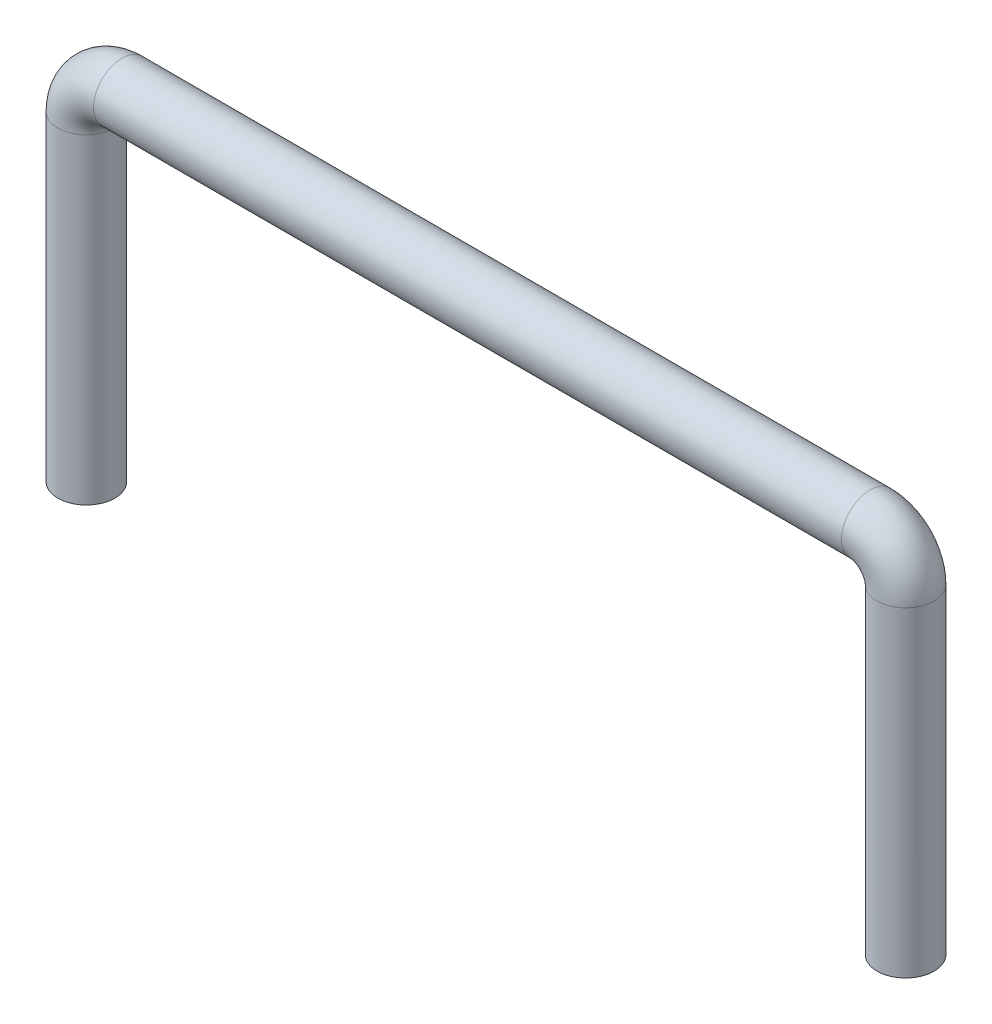
from build123d import *

# Parameters (mm, degrees)
SKETCH1_R = 0.4


with BuildPart() as part:
    # Sweep1: sweep along a path in Sketch4
    with BuildLine(Plane.XY) as sweep1_path:
        Line((0, 0), (0, 4.5))
        ThreePointArc((0, 4.5), (0.146446609, 4.853553391), (0.5, 5))
        Line((0.5, 5), (11, 5))
        ThreePointArc((11, 5), (11.353553391, 4.853553391), (11.5, 4.5))
        Line((11.5, 4.5), (11.5, 0))
    # Sketch1 → Sweep1 (sweep)
    with BuildSketch(Plane(origin=(0, 0, 0), x_dir=(1, 0, 0), z_dir=(0, 1, 0))):
        Circle(SKETCH1_R)
    sweep(path=sweep1_path.line)


solid = part.part
